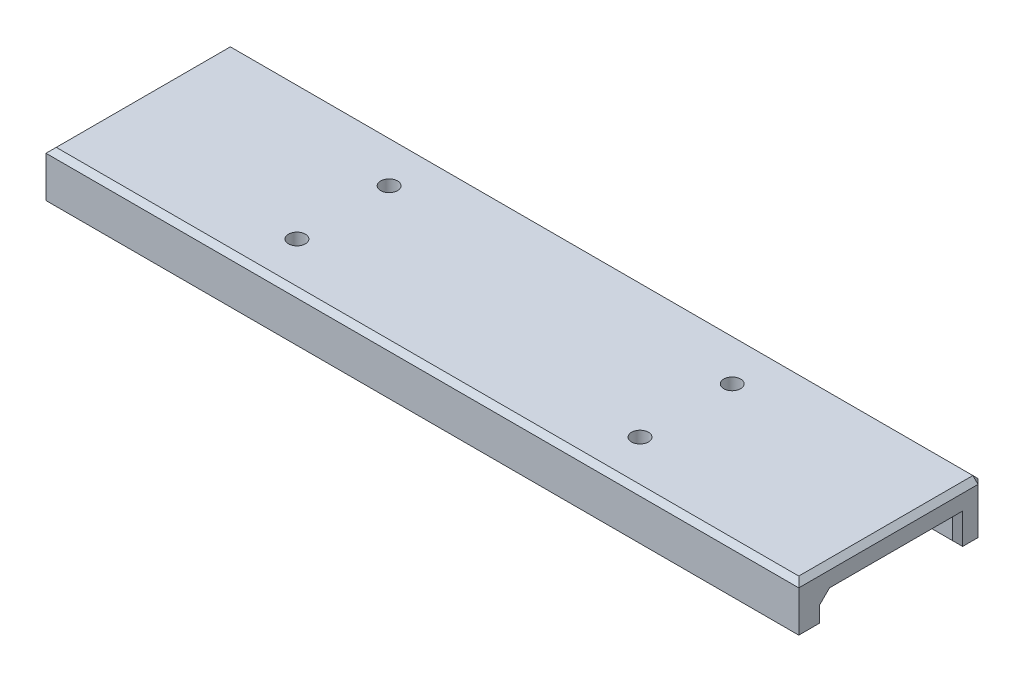
from build123d import *

# Parameters (mm, degrees)
SKETCH1_W                       = 147
SKETCH1_H                       = 36
BOSS_EXTRUDE1_DEPTH             = 5
SKETCH2_W                       = 26
SKETCH2_H                       = 5
CUT_EXTRUDE1_DEPTH              = 74.5
CUT_EXTRUDE1_DEPTH_BACK         = 74.5
CHAMFER1_SIZE                   = 1
TAP_DRILL_FOR_M4X0_7_TAP1_D     = 3.3
TAP_DRILL_FOR_M4X0_7_TAP1_DEPTH = 14
TAP_DRILL_FOR_M4X0_7_TAP1_TIP   = 0.991420021


with BuildPart() as part:
    # Sketch1 → Boss-Extrude1 (new body, symmetric)
    with BuildSketch(Plane(origin=(0, 0, 0), x_dir=(1, 0, 0), z_dir=(0, 1, 0))):
        Rectangle(SKETCH1_W, SKETCH1_H)
    extrude(amount=BOSS_EXTRUDE1_DEPTH, both=True)

    # Sketch2 → Cut-Extrude1 (cut, two sides)
    with BuildSketch(Plane(origin=(0, 0, 0), x_dir=(0, 0, -1), z_dir=(1, 0, 0))) as cut_extrude1_sk:
        with Locations((0, -2.5)):
            Rectangle(SKETCH2_W, SKETCH2_H)
    extrude(amount=CUT_EXTRUDE1_DEPTH, mode=Mode.SUBTRACT)
    extrude(cut_extrude1_sk.sketch, amount=-CUT_EXTRUDE1_DEPTH_BACK, mode=Mode.SUBTRACT)

    # Chamfer1
    chamfer1_edges = [part.edges().sort_by_distance(p)[0] for p in [
        (73.5, -2.5, 13),
        (0, -5, 18),
        (0, 0, 13),
        (73.5, 0, 0),
        (73.5, -2.5, -13),
        (0, -5, -13),
        (-73.5, -2.5, -13),
        (-73.5, 0, 0),
        (-73.5, -2.5, 13),
        (-73.5, -5, 15.5),
        (0, -5, 13),
        (73.5, -5, 15.5),
        (0, 5, 18),
        (-73.5, 5, 0),
        (73.5, 5, 0),
        (0, 5, -18),
        (73.5, 0, -18),
        (0, -5, -18),
        (-73.5, 0, -18),
    ]]
    chamfer(chamfer1_edges, length=CHAMFER1_SIZE)

    # Tap Drill for M4x0.7 Tap1
    with Locations(Plane(origin=(-88.5, 5, -18), x_dir=(-1, 0, 0), z_dir=(0, 1, 0))):
        with Locations((-55, 27), (-122, 27), (-55, 9), (-122, 9)):
            Hole(TAP_DRILL_FOR_M4X0_7_TAP1_D / 2, depth=TAP_DRILL_FOR_M4X0_7_TAP1_DEPTH)
            with Locations((0, 0, -(TAP_DRILL_FOR_M4X0_7_TAP1_DEPTH + TAP_DRILL_FOR_M4X0_7_TAP1_TIP / 2))):  # 118° drill point
                Cone(0, TAP_DRILL_FOR_M4X0_7_TAP1_D / 2, TAP_DRILL_FOR_M4X0_7_TAP1_TIP, mode=Mode.SUBTRACT)


solid = part.part
